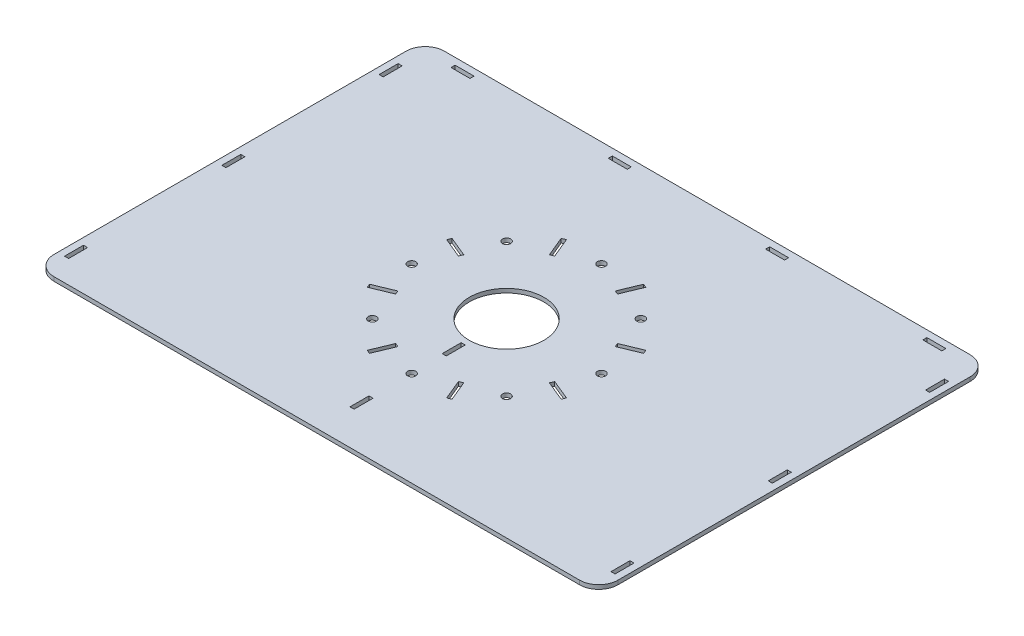
from build123d import *

# Parameters (mm, degrees)
BOSS_EXTRUDE1_DEPTH = 3
CUT_EXTRUDE1_DEPTH  = 3
SKETCH3_R           = 27.5
CUT_EXTRUDE2_DEPTH  = 3
CIRPATTERN1_COUNT   = 8
SKETCH5_R           = 3
CUT_EXTRUDE4_DEPTH  = 3
CIRPATTERN2_COUNT   = 8
SKETCH6_W           = 14
SKETCH6_H           = 3
CUT_EXTRUDE7_DEPTH  = 3
SKETCH8_W           = 3
SKETCH8_H           = 14
CUT_EXTRUDE8_DEPTH  = 3
SKETCH10_W          = 3
SKETCH10_H          = 14
CUT_EXTRUDE9_DEPTH  = 3


with BuildPart() as part:
    # Sketch1 → Boss-Extrude1 (new body)
    with BuildSketch(Plane(origin=(0, 0, 0), x_dir=(1, 0, 0), z_dir=(0, 1, 0))):
        with BuildLine():
            Line((-193.857864376, -140), (193.857864376, -140))
            ThreePointArc((193.857864376, -140), (203.857864376, -135.857864376), (208, -125.857864376))
            Line((208, -125.857864376), (208, 133.857864376))
            ThreePointArc((208, 133.857864376), (203.857864376, 143.857864376), (193.857864376, 148))
            Line((193.857864376, 148), (-193.857864376, 148))
            ThreePointArc((-193.857864376, 148), (-203.857864376, 143.857864376), (-208, 133.857864376))
            Line((-208, 133.857864376), (-208, -125.857864376))
            ThreePointArc((-208, -125.857864376), (-203.857864376, -135.857864376), (-193.857864376, -140))
        make_face()
    extrude(amount=BOSS_EXTRUDE1_DEPTH)

    # Sketch2 → Cut-Extrude1 (cut)
    with BuildSketch(Plane(origin=(0, 3, 0), x_dir=(1, 0, 0), z_dir=(0, 1, 0))):
        Polygon((-31.227780816, 71.471989723), (-28.456142219, 72.62004002), (-22.333207301, 57.8379675), (-25.104845898, 56.689917202), align=None)
    cut_extrude1 = extrude(amount=-CUT_EXTRUDE1_DEPTH, mode=Mode.SUBTRACT)

    # Sketch3 → Cut-Extrude2 (cut)
    with BuildSketch(Plane(origin=(0, 3, 0), x_dir=(1, 0, 0), z_dir=(0, 1, 0))):
        Circle(SKETCH3_R)
    extrude(amount=-CUT_EXTRUDE2_DEPTH, mode=Mode.SUBTRACT)

    # CirPattern1: Cut-Extrude1 ×8 about axis
    cirpattern1_axis = Axis((0, 0, 0), (0, 1, 0))
    for i in range(1, CIRPATTERN1_COUNT):
        add(cut_extrude1.rotate(cirpattern1_axis, i * 360 / CIRPATTERN1_COUNT), mode=Mode.SUBTRACT)

    # Sketch5 → Cut-Extrude4 (cut)
    with BuildSketch(Plane(origin=(0, 3, 0), x_dir=(1, 0, 0), z_dir=(0, 1, 0))):
        with Locations((0, 70)):
            Circle(SKETCH5_R)
    cut_extrude4 = extrude(amount=-CUT_EXTRUDE4_DEPTH, mode=Mode.SUBTRACT)

    # CirPattern2: Cut-Extrude4 ×8 about axis
    cirpattern2_axis = Axis((0, 0, 0), (0, 1, 0))
    for i in range(1, CIRPATTERN2_COUNT):
        add(cut_extrude4.rotate(cirpattern2_axis, i * 360 / CIRPATTERN2_COUNT), mode=Mode.SUBTRACT)

    # Sketch6 → Cut-Extrude7 (cut)
    with BuildSketch(Plane(origin=(0, 3, 0), x_dir=(1, 0, 0), z_dir=(0, 1, 0))):
        with Locations((174, 141.5)):
            Rectangle(SKETCH6_W, SKETCH6_H)
        with Locations((-174, 141.5)):
            Rectangle(SKETCH6_W, SKETCH6_H)
        with Locations((58, 141.5)):
            Rectangle(SKETCH6_W, SKETCH6_H)
        with Locations((-58, 141.5)):
            Rectangle(SKETCH6_W, SKETCH6_H)
    extrude(amount=-CUT_EXTRUDE7_DEPTH, mode=Mode.SUBTRACT)

    # Sketch8 → Cut-Extrude8 (cut)
    with BuildSketch(Plane(origin=(0, 3, 0), x_dir=(1, 0, 0), z_dir=(0, 1, 0))):
        with Locations((201.5, 116)):
            Rectangle(SKETCH8_W, SKETCH8_H)
        with Locations((-201.5, 116)):
            Rectangle(SKETCH8_W, SKETCH8_H)
        with Locations((201.5, 0)):
            Rectangle(SKETCH8_W, SKETCH8_H)
        with Locations((-201.5, 0)):
            Rectangle(SKETCH8_W, SKETCH8_H)
        with Locations((201.5, -116)):
            Rectangle(SKETCH8_W, SKETCH8_H)
        with Locations((-201.5, -116)):
            Rectangle(SKETCH8_W, SKETCH8_H)
    extrude(amount=-CUT_EXTRUDE8_DEPTH, mode=Mode.SUBTRACT)

    # Sketch10 → Cut-Extrude9 (cut)
    with BuildSketch(Plane(origin=(0, 3, 0), x_dir=(1, 0, 0), z_dir=(0, 1, 0))):
        with Locations((0, -39)):
            Rectangle(SKETCH10_W, SKETCH10_H)
        with Locations((0, -107)):
            Rectangle(SKETCH10_W, SKETCH10_H)
    extrude(amount=-CUT_EXTRUDE9_DEPTH, mode=Mode.SUBTRACT)


solid = part.part
